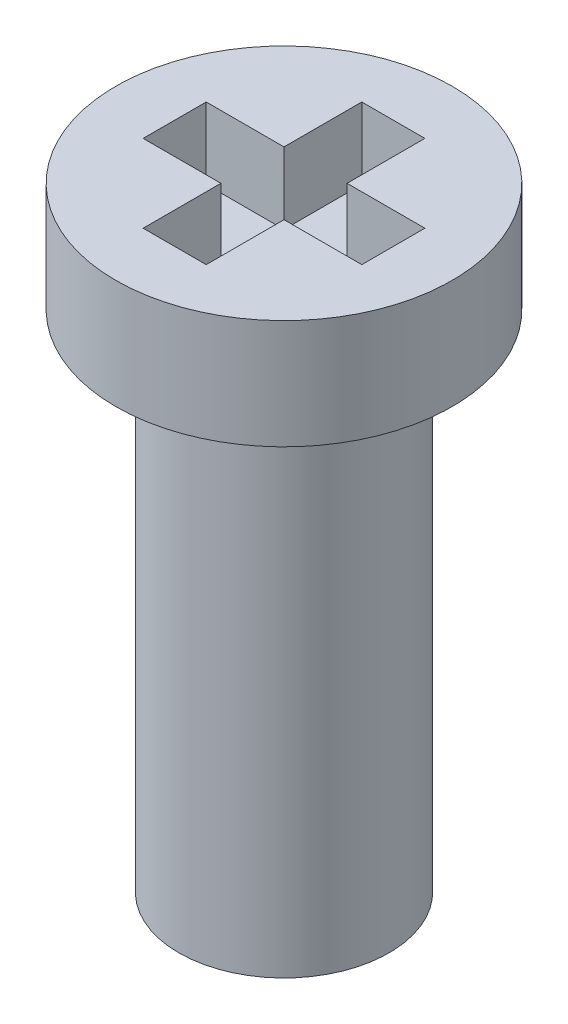
from build123d import *

# Parameters (mm, degrees)
CUT_EXTRUDE1_DEPTH = 0.85


with BuildPart() as part:
    # Sketch1 → Revolve1 (revolve)
    with BuildSketch(Plane(origin=(0, 0, 0), x_dir=(0, 0, -1), z_dir=(1, 0, 0))):
        Polygon((0, 7.3), (2, 7.3), (2, 6), (1.25, 6), (1.25, 0), (0, 0), align=None)
    revolve(axis=Axis((0, 0, 0), (0, 1, 0)))

    # Sketch4 → Cut-Extrude1 (cut)
    with BuildSketch(Plane(origin=(0, 7.3, 0), x_dir=(1, 0, 0), z_dir=(0, 1, 0))):
        Polygon((0.375, -0.375), (0.375, -1.3), (-0.375, -1.3), (-0.375, -0.375), (-1.3, -0.375), (-1.3, 0.375), (-0.375, 0.375), (-0.375, 1.3), (0.375, 1.3), (0.375, 0.375), (1.3, 0.375), (1.3, -0.375), align=None)
    extrude(amount=-CUT_EXTRUDE1_DEPTH, mode=Mode.SUBTRACT)


solid = part.part
